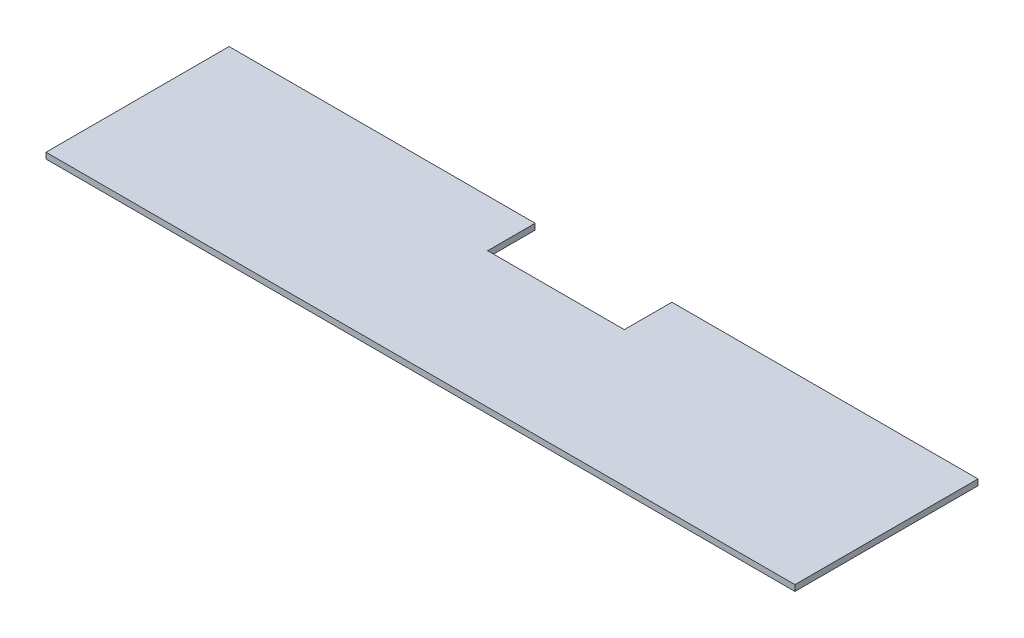
from build123d import *

# Parameters (mm, degrees)
SKETCH5_W           = 381
SKETCH5_H           = 195.58
BOSS_EXTRUDE2_DEPTH = 6.35
SKETCH6_W           = 209.55
SKETCH6_H           = 195.58
BOSS_EXTRUDE3_DEPTH = 6.35
SKETCH7_W           = 209.55
SKETCH7_H           = 195.58
BOSS_EXTRUDE4_DEPTH = 6.35
SKETCH9_W           = 146.05
SKETCH9_H           = 50.8
CUT_EXTRUDE1_DEPTH  = 7.35


with BuildPart() as part:
    # Sketch5 → Boss-Extrude2 (new body)
    with BuildSketch(Plane(origin=(0, 0, 0), x_dir=(1, 0, 0), z_dir=(0, 1, 0))):
        with Locations((190.5, 97.79)):
            Rectangle(SKETCH5_W, SKETCH5_H)
    extrude(amount=BOSS_EXTRUDE2_DEPTH)

    # Sketch6 → Boss-Extrude3 (add)
    with BuildSketch(Plane(origin=(0, 0, 0), x_dir=(1, 0, 0), z_dir=(0, 1, 0))):
        with Locations((485.775, 97.79)):
            Rectangle(SKETCH6_W, SKETCH6_H)
    extrude(amount=BOSS_EXTRUDE3_DEPTH)

    # Sketch7 → Boss-Extrude4 (add)
    with BuildSketch(Plane(origin=(0, 0, 0), x_dir=(1, 0, 0), z_dir=(0, 1, 0))):
        with Locations((-104.775, 97.79)):
            Rectangle(SKETCH7_W, SKETCH7_H)
    extrude(amount=BOSS_EXTRUDE4_DEPTH)

    # Sketch9 → Cut-Extrude1 (cut, through all)
    with BuildSketch(Plane(origin=(0, 6.35, 0), x_dir=(1, 0, 0), z_dir=(0, 1, 0))):
        with Locations((190.5, 170.18)):
            Rectangle(SKETCH9_W, SKETCH9_H)
    extrude(amount=-CUT_EXTRUDE1_DEPTH, mode=Mode.SUBTRACT)


solid = part.part
